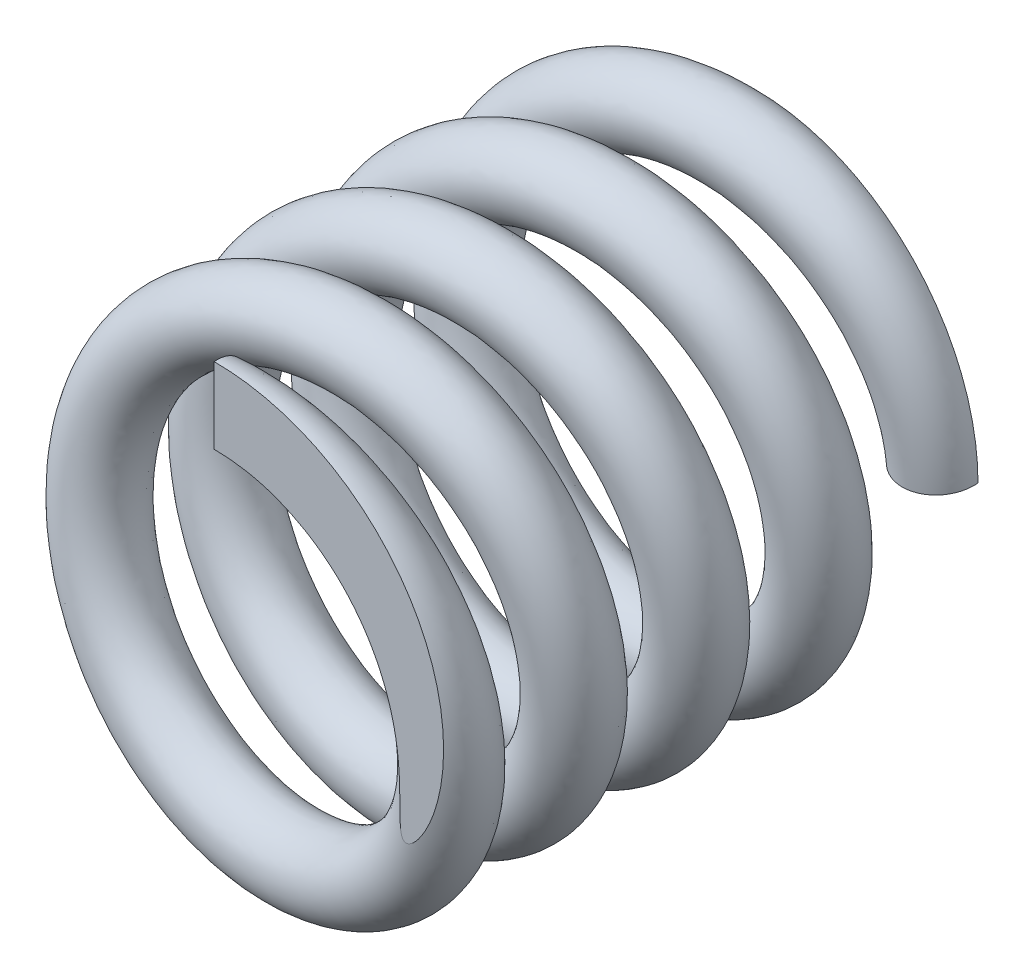
from build123d import *

# Parameters (mm, degrees)
SWEEP1_PITCH            = 4
SWEEP1_HEIGHT           = 17
SWEEP1_RADIUS           = 6.7
SWEEP1_START_ANGLE      = 90
SKETCH3_R               = 1.24
SKETCH4_W               = 18.388584742
SKETCH4_H               = 3.490349357
SKETCH4_H_2             = 3.172480621
CUT_EXTRUDE1_DEPTH      = 8.957243773
CUT_EXTRUDE1_DEPTH_BACK = 8.95722852


with BuildPart() as part:
    # Sweep1: sweep along a helix
    with BuildLine() as sweep1_path:
        add(Helix(SWEEP1_PITCH, SWEEP1_HEIGHT, SWEEP1_RADIUS, center=(0, 0, 0), direction=(0, 0, -1), mode=Mode.PRIVATE).rotate(Axis((0, 0, 0), (0, 0, -1)), SWEEP1_START_ANGLE))
    # Sketch3 → Sweep1 (sweep)
    with BuildSketch(Plane(origin=(0, 6.7, 0), x_dir=(-0.09459183, 0, -0.99551614), z_dir=(0.99551614, 0, -0.09459183))):
        with Locations((0, 0.017218173)):
            Circle(SKETCH3_R)
    sweep(path=sweep1_path.line, is_frenet=True)

    # Sketch4 → Cut-Extrude1 (cut, two sides)
    with BuildSketch(Plane(origin=(0, 0, 0), x_dir=(1, 0, 0), z_dir=(0, 1, 0))) as cut_extrude1_sk:
        with Locations((0.518350738, 18.745174678)):
            Rectangle(SKETCH4_W, SKETCH4_H)
        with Locations((0.518350738, -1.586240311)):
            Rectangle(SKETCH4_W, SKETCH4_H_2)
    extrude(amount=CUT_EXTRUDE1_DEPTH, mode=Mode.SUBTRACT)
    extrude(cut_extrude1_sk.sketch, amount=-CUT_EXTRUDE1_DEPTH_BACK, mode=Mode.SUBTRACT)


solid = part.part
